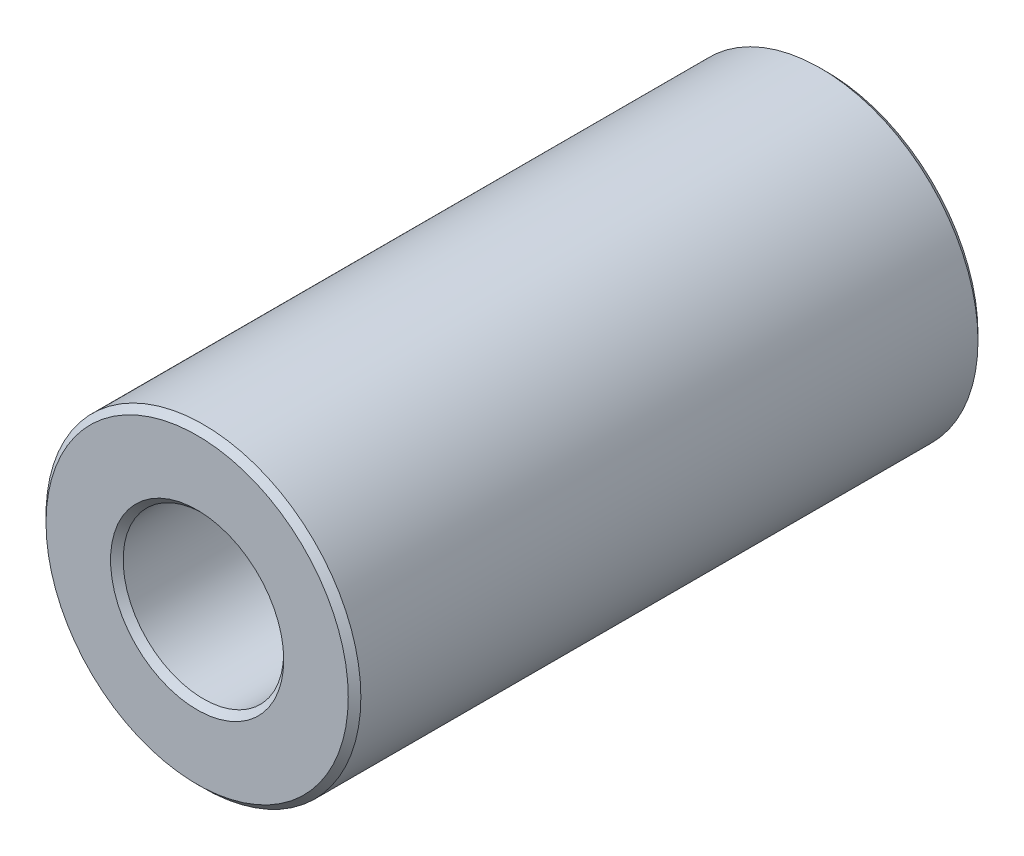
from build123d import *

# Parameters (mm, degrees)
SKETCH1_R           = 5
SKETCH1_R_2         = 2.55
BOSS_EXTRUDE1_DEPTH = 20
CHAMFER1_SIZE       = 0.2


with BuildPart() as part:
    # Sketch1 → Boss-Extrude1 (new body)
    with BuildSketch(Plane.XY):
        Circle(SKETCH1_R)
        Circle(SKETCH1_R_2, mode=Mode.SUBTRACT)
    extrude(amount=BOSS_EXTRUDE1_DEPTH)

    # Chamfer1
    chamfer1_edges = [part.edges().sort_by_distance(p)[0] for p in [
        (-5, 0, 0),
        (-5, 0, 20),
        (-2.55, 0, 0),
        (-2.55, 0, 20),
    ]]
    chamfer(chamfer1_edges, length=CHAMFER1_SIZE)


solid = part.part
